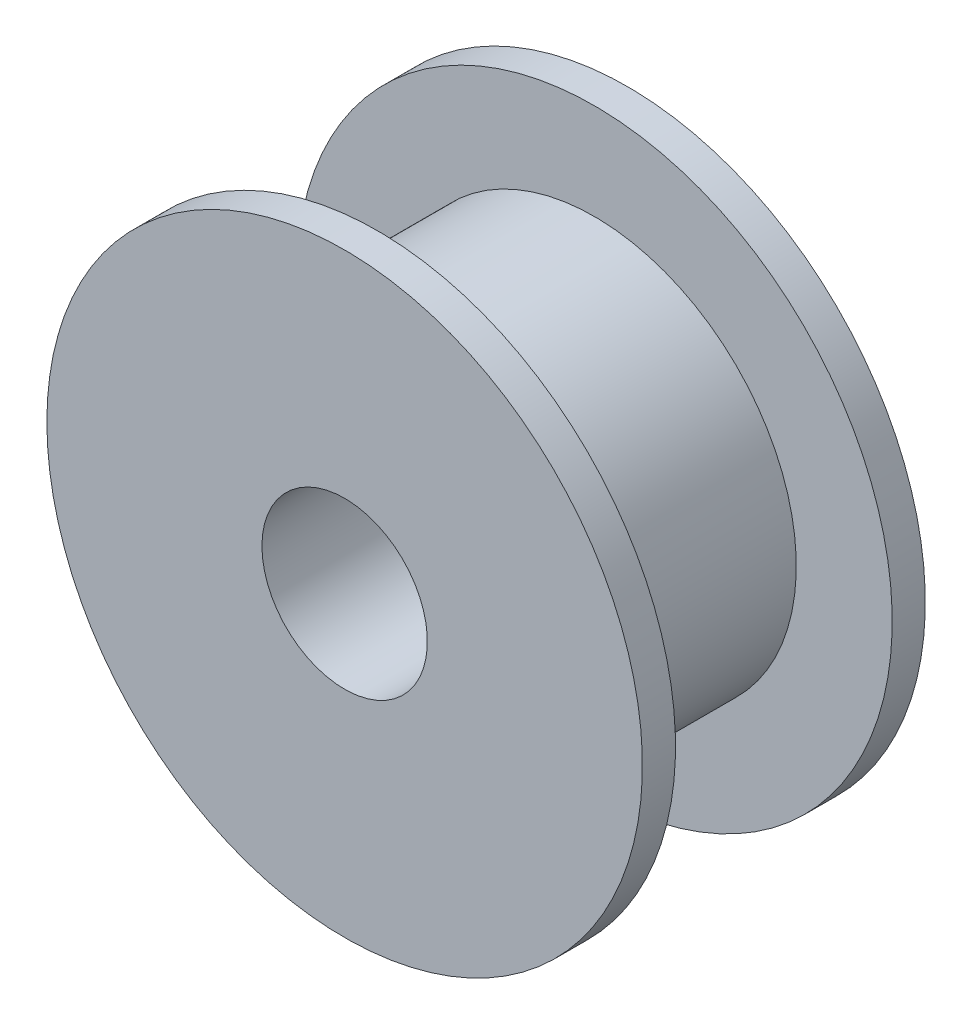
from build123d import *


with BuildPart() as part:
    # Sketch2 → Revolve1 (revolve)
    with BuildSketch(Plane(origin=(0, 0, 0), x_dir=(1, 0, 0), z_dir=(0, 1, 0))):
        Polygon((-9, 4.275), (-2.5, 4.275), (-2.5, -4.275), (-9, -4.275), (-9, -3.275), (-6.1, -3.275), (-6.1, 3.275), (-9, 3.275), align=None)
    revolve(axis=Axis((0, 0, -4.275), (0, 0, 1)))


solid = part.part
